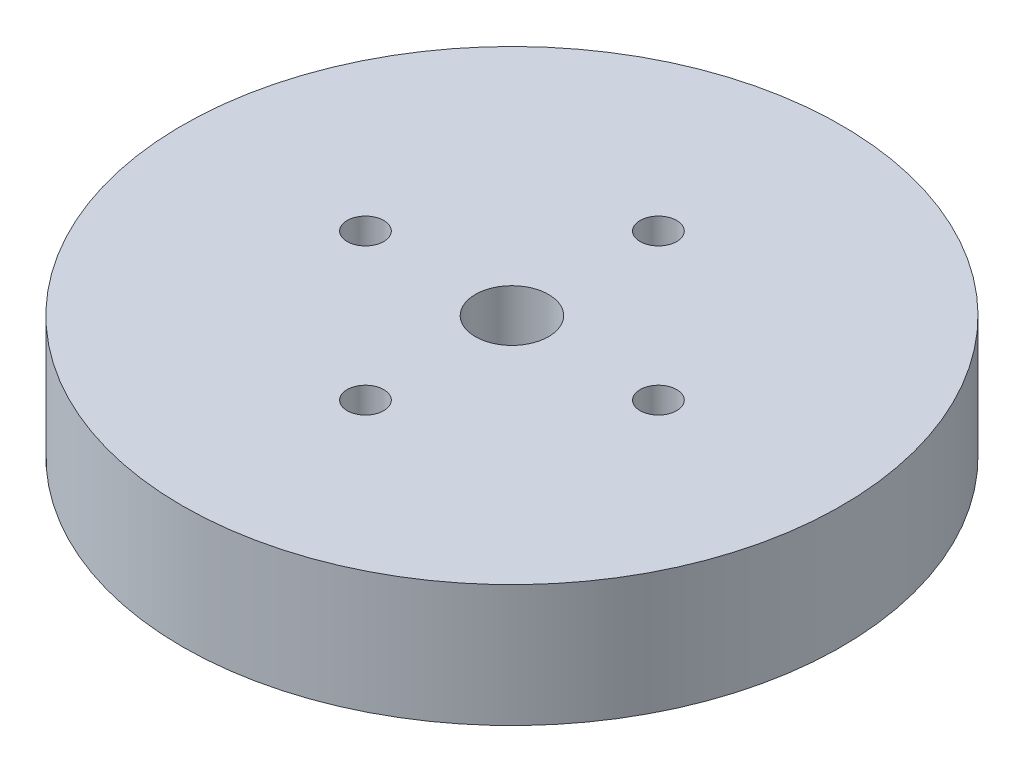
from build123d import *

# Parameters (mm, degrees)
SKETCH1_R           = 13.5
SKETCH1_R_2         = 1.5
BOSS_EXTRUDE2_DEPTH = 5
SKETCH2_R           = 0.75
CUT_EXTRUDE1_DEPTH  = 34


with BuildPart() as part:
    # Sketch1 → Boss-Extrude2 (new body)
    with BuildSketch(Plane(origin=(0, 0, 0), x_dir=(1, 0, 0), z_dir=(0, 1, 0))):
        Circle(SKETCH1_R)
        Circle(SKETCH1_R_2, mode=Mode.SUBTRACT)
    extrude(amount=BOSS_EXTRUDE2_DEPTH)

    # Sketch2 → Cut-Extrude1 (cut)
    with BuildSketch(Plane(origin=(0, 5, 0), x_dir=(1, 0, 0), z_dir=(0, 1, 0))):
        with Locations((6, 0)):
            Circle(SKETCH2_R)
        with Locations((0, -6)):
            Circle(SKETCH2_R)
        with Locations((-6, 0)):
            Circle(SKETCH2_R)
        with Locations((0, 6)):
            Circle(SKETCH2_R)
    extrude(amount=-CUT_EXTRUDE1_DEPTH, mode=Mode.SUBTRACT)


solid = part.part
